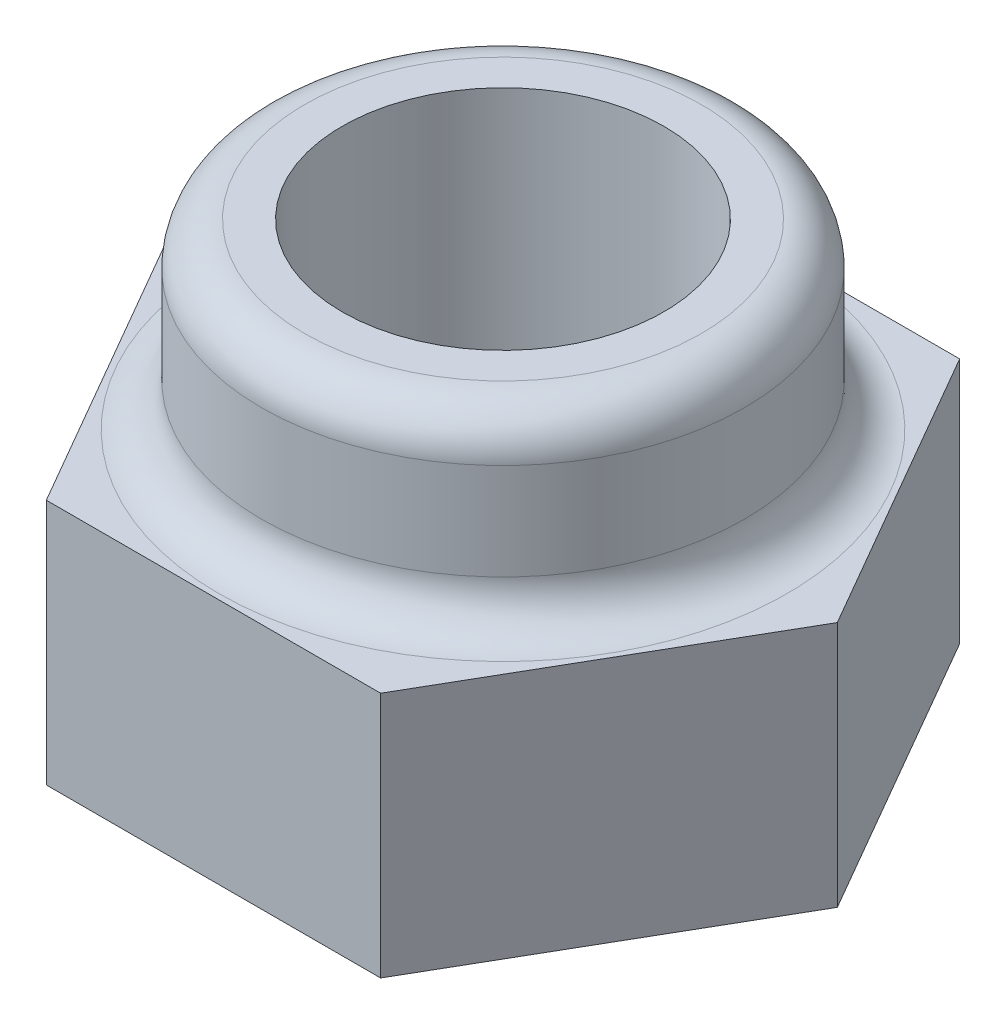
from build123d import *

# Parameters (mm, degrees)
SKETCH_1_R      = 1.5
EXTRUDE_1_DEPTH = 2.3
SKETCH_2_R      = 2.25
SKETCH_2_R_2    = 1.5
EXTRUDE_2_DEPTH = 1.7
FILLET_1_R      = 0.4


with BuildPart() as part:
    # 草图1 → 凸台-拉伸1 (new body)
    with BuildSketch(Plane(origin=(0, 0, 0), x_dir=(1, 0, 0), z_dir=(0, 1, 0))):
        Polygon((3.117691454, 0), (1.558845727, 2.7), (-1.558845727, 2.7), (-3.117691454, 0), (-1.558845727, -2.7), (1.558845727, -2.7), align=None)
        Circle(SKETCH_1_R, mode=Mode.SUBTRACT)
    extrude(amount=EXTRUDE_1_DEPTH)

    # 草图2 → 凸台-拉伸2 (add)
    with BuildSketch(Plane(origin=(0, 2.3, 0), x_dir=(1, 0, 0), z_dir=(0, 1, 0))):
        Circle(SKETCH_2_R)
        Circle(SKETCH_2_R_2, mode=Mode.SUBTRACT)
    extrude(amount=EXTRUDE_2_DEPTH)

    # 圆角1
    fillet_1_edges = [part.edges().sort_by_distance(p)[0] for p in [
        (-2.25, 2.3, 0),
        (-2.25, 4, 0),
    ]]
    fillet(fillet_1_edges, radius=FILLET_1_R)


solid = part.part
